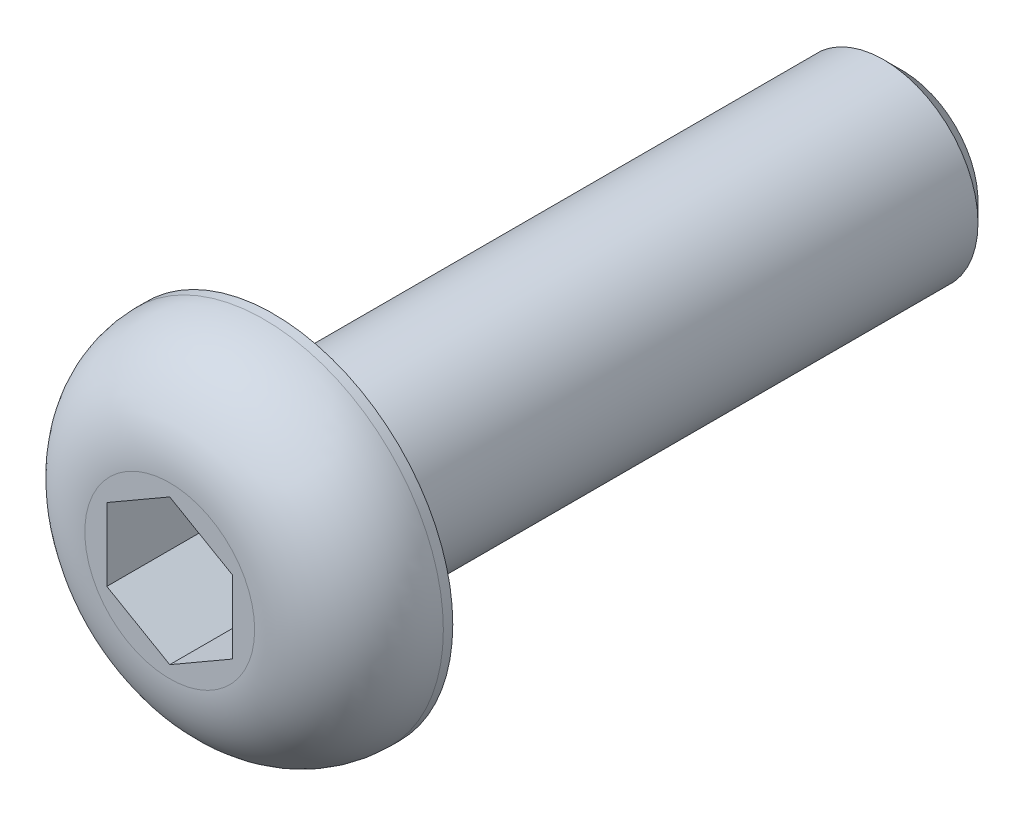
from build123d import *

# Parameters (mm, degrees)
SKETCH1_R           = 2.85
BOSS_EXTRUDE1_DEPTH = 1.65
SKETCH2_R           = 1.5
BOSS_EXTRUDE2_DEPTH = 10
CHAMFER1_SIZE       = 0.3
CUT_EXTRUDE1_DEPTH  = 2
FILLET1_R           = 1.5


with BuildPart() as part:
    # Sketch1 → Boss-Extrude1 (new body)
    with BuildSketch(Plane.XY):
        Circle(SKETCH1_R)
    extrude(amount=BOSS_EXTRUDE1_DEPTH)

    # Sketch2 → Boss-Extrude2 (add)
    with BuildSketch(Plane(origin=(0, 0, 0), x_dir=(-1, 0, 0), z_dir=(0, 0, -1))):
        Circle(SKETCH2_R)
    extrude(amount=BOSS_EXTRUDE2_DEPTH)

    # Chamfer1
    chamfer1_edges = [part.edges().sort_by_distance(p)[0] for p in [
        (1.5, 0, -10),
    ]]
    chamfer(chamfer1_edges, length=CHAMFER1_SIZE)

    # Sketch3 → Cut-Extrude1 (cut)
    with BuildSketch(Plane.XY.offset(1.65)):
        Polygon((0, 1.154700538), (-1, 0.577350269), (-1, -0.577350269), (0, -1.154700538), (1, -0.577350269), (1, 0.577350269), align=None)
    extrude(amount=-CUT_EXTRUDE1_DEPTH, mode=Mode.SUBTRACT)

    # Fillet1
    fillet1_edges = [part.edges().sort_by_distance(p)[0] for p in [
        (-2.85, 0, 1.65),
    ]]
    fillet(fillet1_edges, radius=FILLET1_R)


solid = part.part
